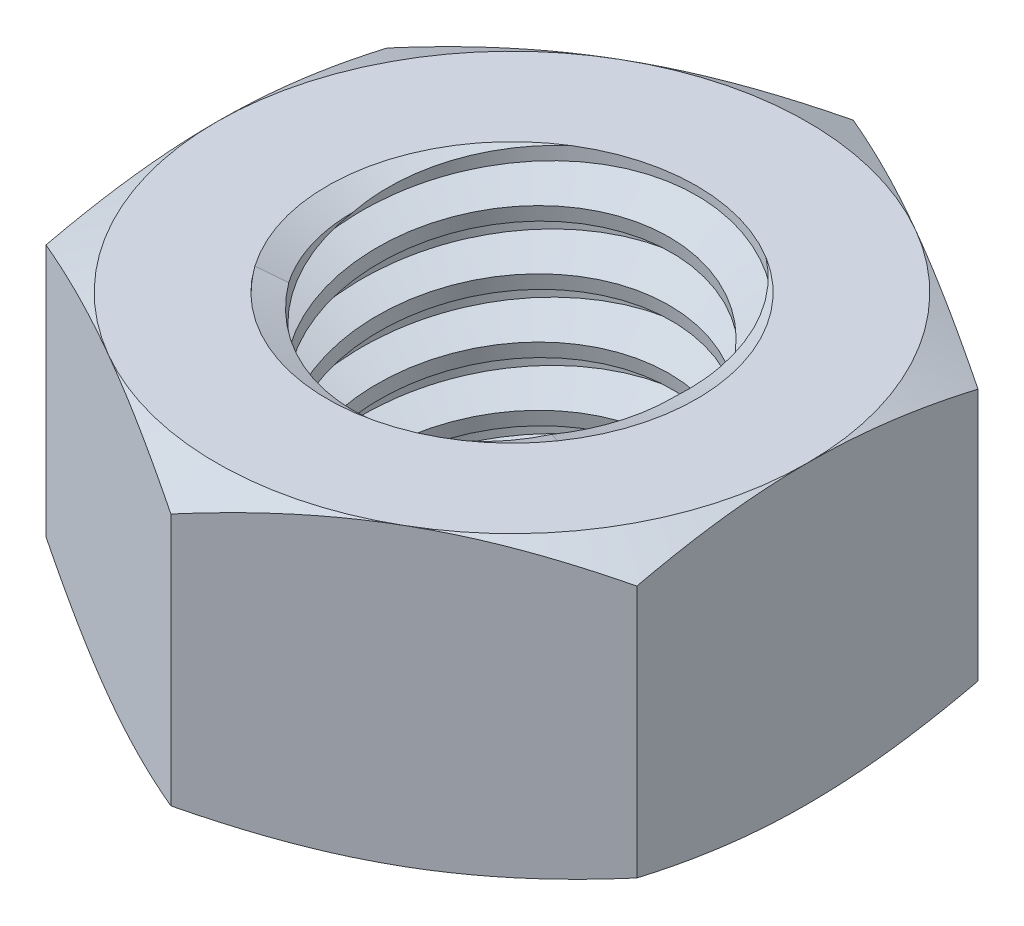
from build123d import *

# Parameters (mm, degrees)
EXTRUDE1_DEPTH      = 2
SKETCH2_W           = 2.5
SKETCH2_H           = 4
LPATTERN1_COUNT     = 5
LPATTERN1_PITCH     = 0.8
LPATTERN1_COL_COUNT = 2
LPATTERN1_COL_PITCH = 0.8


with BuildPart() as part:
    # Sketch1 → Extrude1 (new body, symmetric)
    with BuildSketch(Plane(origin=(0, 0, 0), x_dir=(1, 0, 0), z_dir=(0, 1, 0))):
        Polygon((0, 4.618802154), (-4, 2.309401077), (-4, -2.309401077), (0, -4.618802154), (4, -2.309401077), (4, 2.309401077), align=None)
    extrude(amount=EXTRUDE1_DEPTH, both=True)

    # Sketch4 → Cut-Revolve2 (revolve, cut)
    with BuildSketch(Plane(origin=(0, 0, 0), x_dir=(0, 0, -1), z_dir=(1, 0, 0))):
        Polygon((0, 2), (2.5, 2), (2.127722339, 1.826404076), (2.127722339, -1.826404076), (2.5, -2), (0, -2), align=None)
    revolve(axis=Axis((0, 2, 0), (0, 1, 0)), mode=Mode.SUBTRACT)


with BuildPart() as body_2:
    # Sketch2 → Revolve1 (revolve)
    with BuildSketch(Plane(origin=(0, 0, 0), x_dir=(0, 0, -1), z_dir=(1, 0, 0))):
        with Locations((1.25, 0)):
            Rectangle(SKETCH2_W, SKETCH2_H)
    revolve(axis=Axis((0, -4.5, 0), (0, 1, 0)))

    # Sketch3 → Cut-Revolve1 (revolve, cut)
    with BuildSketch(Plane(origin=(0, 0, 0), x_dir=(0, 0, -1), z_dir=(1, 0, 0))):
        Polygon((2.51579905, 1.901255937), (2.626392401, 1.210047494), (2.15932044, 1.388495759), (2.127722339, 1.585983885), align=None)
    cut_revolve1 = revolve(axis=Axis((0, 2, 0.136915776), (0, -0.987440632, -0.157990501)), mode=Mode.SUBTRACT)

    # LPattern1: Cut-Revolve1 ×5
    with Locations(*[(0, -i * LPATTERN1_PITCH, 0) for i in range(1, LPATTERN1_COUNT)]):
        add(cut_revolve1, mode=Mode.SUBTRACT)

    # LPattern1 col: Cut-Revolve1 ×2
    with Locations(*[(0, i * LPATTERN1_COL_PITCH, 0) for i in range(1, LPATTERN1_COL_COUNT)]):
        add(cut_revolve1, mode=Mode.SUBTRACT)


with BuildPart() as part_1:
    add(part.part)

    # Combine1: cut body 2
    add(body_2.part, mode=Mode.SUBTRACT)

    # Sketch5 → Cut-Revolve3 (revolve, cut)
    with BuildSketch(Plane(origin=(0, 0, 0), x_dir=(0, 0, -1), z_dir=(1, 0, 0))):
        Polygon((0, -2), (4, -2), (4.618802154, -1.711447817), (4.618802154, 1.711447817), (4, 2), (0, 2), (0, 3.27), (5.888802154, 3.27), (5.888802154, -3.27), (0, -3.27), align=None)
    revolve(axis=Axis((0, -2, 0), (0, 1, 0)), mode=Mode.SUBTRACT)


solid = part_1.part
